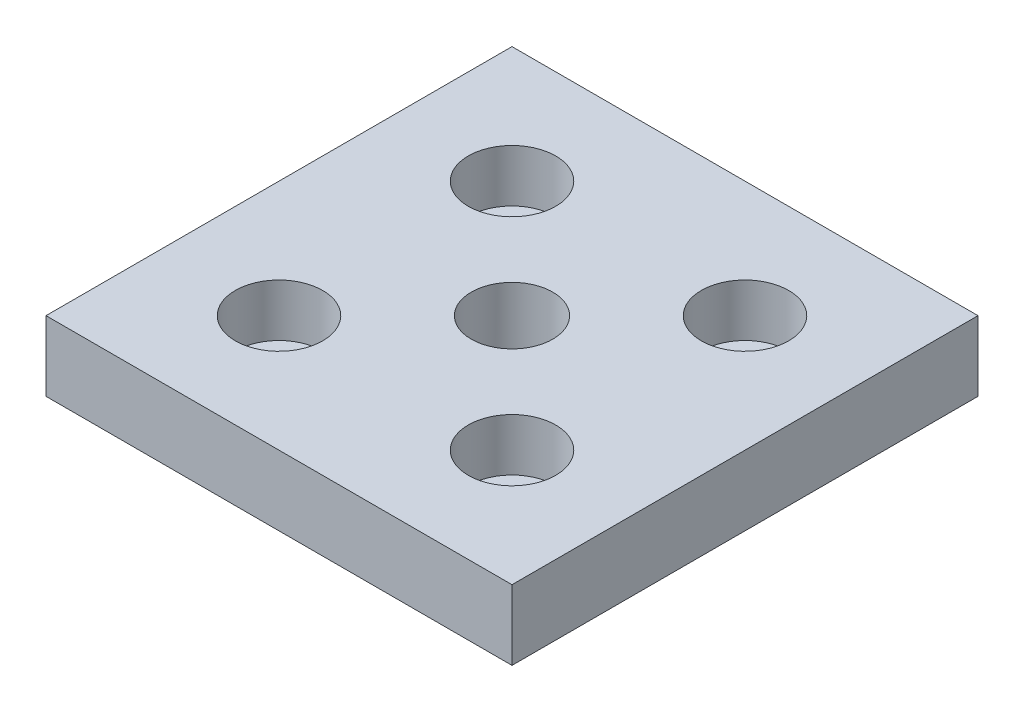
from build123d import *

# Parameters (mm, degrees)
SKETCH_1_W             = 80
SKETCH_1_H             = 80
EXTRUDE_1_DEPTH        = 12
HOLE_WIZARD_M161_D     = 14
HOLE_WIZARD_M161_DEPTH = 12
SKETCH_12_R            = 4.5
CUT_EXTRUDE_1_DEPTH    = 13
SKETCH_13_R            = 7.5
CUT_EXTRUDE_2_DEPTH    = 9


with BuildPart() as part:
    # Эскиз1 → Бобышка-Вытянуть1 (new body)
    with BuildSketch(Plane(origin=(0, 0, 0), x_dir=(1, 0, 0), z_dir=(0, 1, 0))):
        Rectangle(SKETCH_1_W, SKETCH_1_H)
    extrude(amount=EXTRUDE_1_DEPTH)

    # Отверстие обработанное метчиком M161
    with Locations(Plane(origin=(0, 12, 0), x_dir=(1, 0, 0), z_dir=(0, 1, 0))):
        with Locations((0, 0)):
            Hole(HOLE_WIZARD_M161_D / 2, depth=HOLE_WIZARD_M161_DEPTH)

    # Эскиз12 → Вырез-Вытянуть1 (cut, through all)
    with BuildSketch(Plane(origin=(0, 12, 0), x_dir=(1, 0, 0), z_dir=(0, 1, 0))):
        with Locations(Location((-20, 20, 0), (0, 0, 270))):  # turned: the seam where the file's is
            Circle(SKETCH_12_R)
        with Locations(Location((20, 20, 0), (0, 0, 270))):  # turned: the seam where the file's is
            Circle(SKETCH_12_R)
        with Locations(Location((20, -20, 0), (0, 0, 270))):  # turned: the seam where the file's is
            Circle(SKETCH_12_R)
        with Locations(Location((-20, -20, 0), (0, 0, 270))):  # turned: the seam where the file's is
            Circle(SKETCH_12_R)
    extrude(amount=-CUT_EXTRUDE_1_DEPTH, mode=Mode.SUBTRACT)

    # Эскиз13 → Вырез-Вытянуть2 (cut)
    with BuildSketch(Plane(origin=(0, 12, 0), x_dir=(1, 0, 0), z_dir=(0, 1, 0))):
        with Locations(Location((-20, 20, 0), (0, 0, 270))):  # turned: the seam where the file's is
            Circle(SKETCH_13_R)
        with Locations(Location((20, 20, 0), (0, 0, 270))):  # turned: the seam where the file's is
            Circle(SKETCH_13_R)
        with Locations(Location((20, -20, 0), (0, 0, 270))):  # turned: the seam where the file's is
            Circle(SKETCH_13_R)
        with Locations(Location((-20, -20, 0), (0, 0, 270))):  # turned: the seam where the file's is
            Circle(SKETCH_13_R)
    extrude(amount=-CUT_EXTRUDE_2_DEPTH, mode=Mode.SUBTRACT)


solid = part.part
